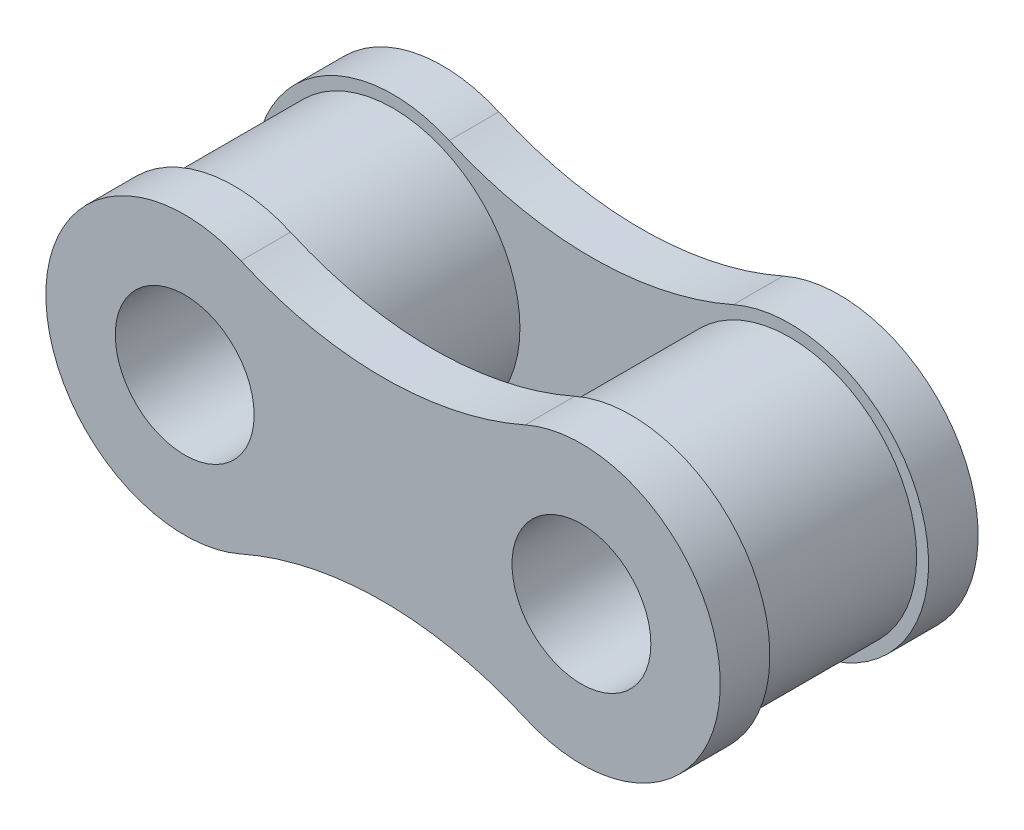
from build123d import *

# Parameters (mm, degrees)
SKETCH1_R             = 5.08
SKETCH1_R_2           = 3.81
BOSS_EXTRUDE1_DEPTH   = 3.175
BOSS_EXTRUDE1_2_DEPTH = 3.175
SKETCH2_R             = 2.778125
BOSS_EXTRUDE2_DEPTH   = 1.984375
SKETCH3_R             = 3.81
SKETCH3_R_2           = 2.778125
BOSS_EXTRUDE3_DEPTH   = 8.334375


with BuildPart() as part:
    # Sketch1 → Boss-Extrude1 (new body, symmetric)
    with BuildSketch(Plane.XY):
        Circle(SKETCH1_R)
        Circle(SKETCH1_R_2, mode=Mode.SUBTRACT)
    extrude(amount=BOSS_EXTRUDE1_DEPTH, both=True)


with BuildPart() as body_2:
    # Sketch1 → Boss-Extrude1 2 (new body, symmetric)
    with BuildSketch(Plane.XY):
        with Locations((15.875, 0)):
            Circle(SKETCH1_R)
        with Locations((15.875, 0)):
            Circle(SKETCH1_R_2, mode=Mode.SUBTRACT)
    extrude(amount=BOSS_EXTRUDE1_2_DEPTH, both=True)


with BuildPart() as body_3:
    # Sketch2 → Boss-Extrude2 (new body)
    with BuildSketch(Plane.XY.offset(3.175)):
        with BuildLine():
            ThreePointArc((2.250669692, 5.08), (-5.55625, 0), (2.250669692, -5.08))
            ThreePointArc((2.250669692, -5.08), (7.9375, -3.876645752), (13.624330308, -5.08))
            ThreePointArc((13.624330308, -5.08), (21.43125, 0), (13.624330308, 5.08))
            ThreePointArc((13.624330308, 5.08), (7.9375, 3.876645752), (2.250669692, 5.08))
        make_face()
        Circle(SKETCH2_R, mode=Mode.SUBTRACT)
        with Locations((15.875, 0)):
            Circle(SKETCH2_R, mode=Mode.SUBTRACT)
    extrude(amount=BOSS_EXTRUDE2_DEPTH)


with BuildPart() as body_4:
    # Mirror1: mirrored copy
    add(body_3.part.mirror(Plane.XY))


    add(body_3.part)  # Boss-Extrude3 merges body 3
    # Sketch3 → Boss-Extrude3 (add)
    with BuildSketch(Plane.XY.offset(-3.175)):
        Circle(SKETCH3_R)
        Circle(SKETCH3_R_2, mode=Mode.SUBTRACT)
        with Locations((15.875, 0)):
            Circle(SKETCH3_R)
        with Locations((15.875, 0)):
            Circle(SKETCH3_R_2, mode=Mode.SUBTRACT)
    extrude(amount=BOSS_EXTRUDE3_DEPTH)


solid = Compound([part.part, body_2.part, body_4.part])
